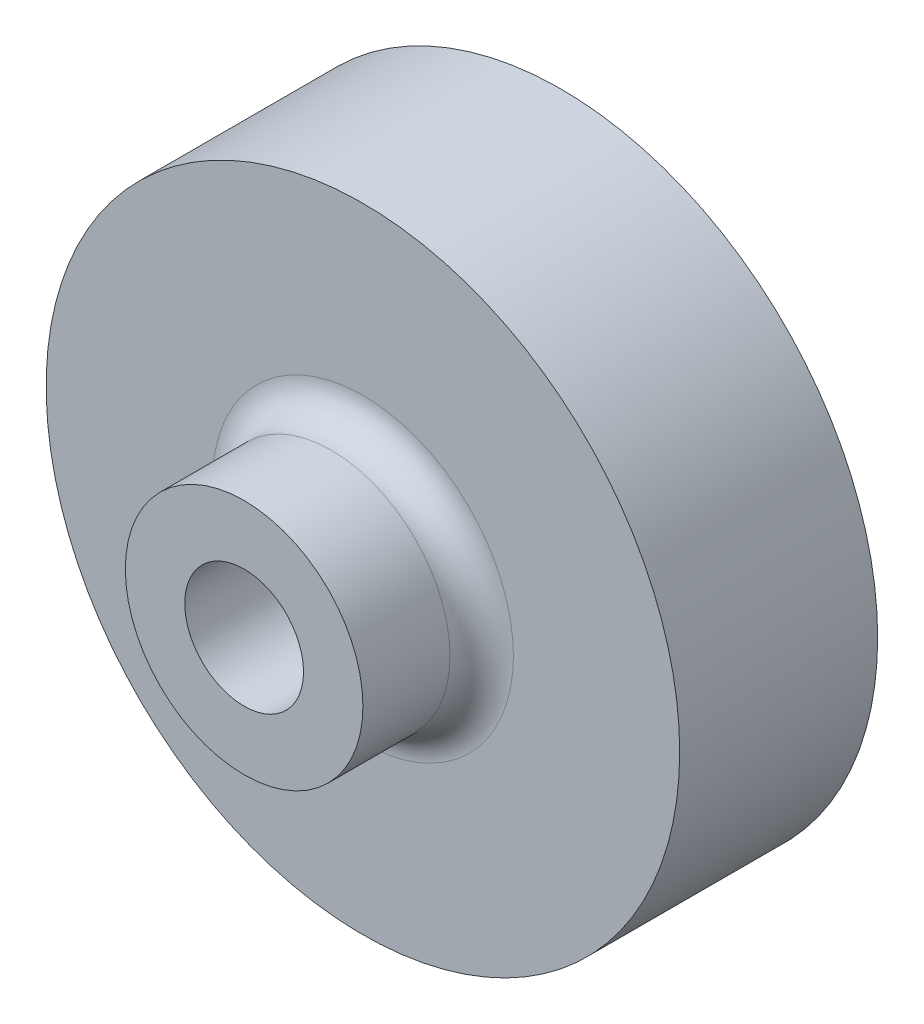
from build123d import *

# Parameters (mm, degrees)
SKETCH1_W          = 3.75
SKETCH1_H          = 3.75
CUT_EXTRUDE1_DEPTH = 1.25
FILLET1_R          = 1
SKETCH3_R          = 1.875
CUT_EXTRUDE2_DEPTH = 8.75


with BuildPart() as part:
    # Sketch1 → Revolve1 (revolve)
    with BuildSketch(Plane(origin=(0, 0, 0), x_dir=(1, 0, 0), z_dir=(0, 1, 0))):
        with Locations((1.875, 1.875)):
            Rectangle(SKETCH1_W, SKETCH1_H)
        Polygon((0, 10), (0, 3.75), (3.75, 3.75), (10, 3.75), (10, 10), align=None)
    revolve(axis=Axis((0, 0, -3.75), (0, 0, -1)))

    # Sketch2 → Cut-Extrude1 (cut)
    with BuildSketch(Plane(origin=(0, 0, -10), x_dir=(-1, 0, 0), z_dir=(0, 0, -1))):
        with BuildLine():
            Line((0.5, 1.807104037), (0.5, -1.807104037))
            ThreePointArc((0.5, -1.807104037), (1.875, 0), (0.5, 1.807104037))
        make_face()
        with BuildLine():
            Line((-0.5, 1.807104037), (-0.5, -1.807104037))
            ThreePointArc((-0.5, -1.807104037), (-1.875, 0), (-0.5, 1.807104037))
        make_face()
    extrude(amount=-CUT_EXTRUDE1_DEPTH, mode=Mode.SUBTRACT)

    # Fillet1
    fillet1_edges = [part.edges().sort_by_distance(p)[0] for p in [
        (-3.75, 0, -3.75),
    ]]
    fillet(fillet1_edges, radius=FILLET1_R)

    # Sketch3 → Cut-Extrude2 (cut)
    with BuildSketch(Plane.XY):
        with Locations(Location((0, 0, 0), (0, 0, 254.533990047))):
            Circle(SKETCH3_R)
    extrude(amount=-CUT_EXTRUDE2_DEPTH, mode=Mode.SUBTRACT)


solid = part.part
